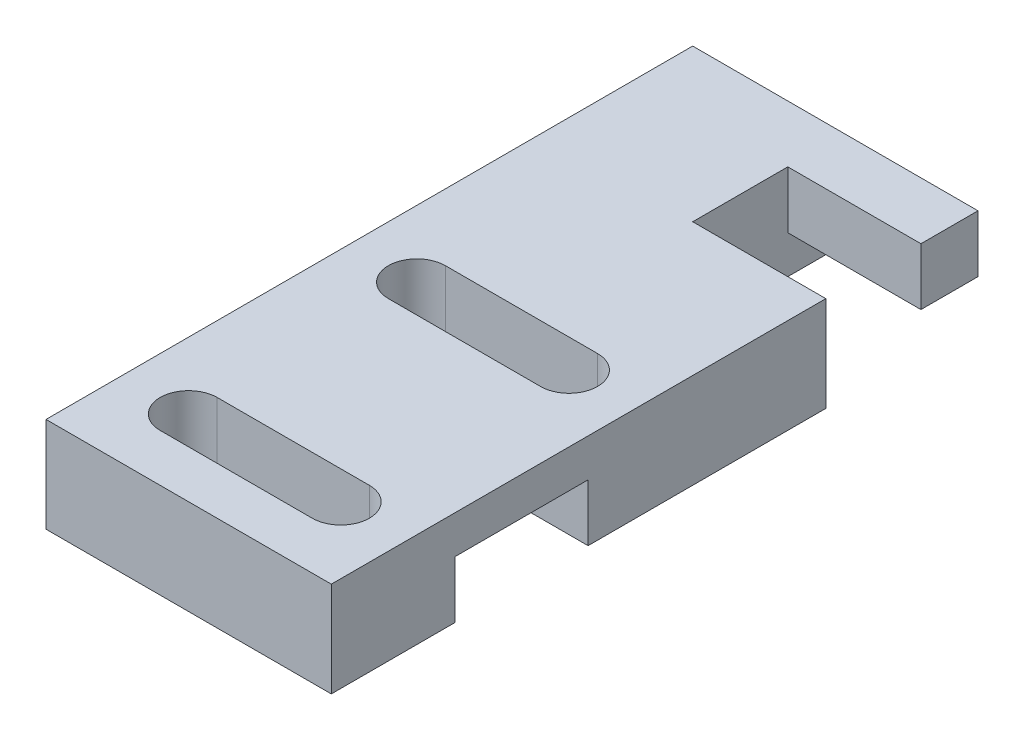
from build123d import *

# Parameters (mm, degrees)
EXTRUDE_1_DEPTH     = 5
SKETCH_2_W          = 7
SKETCH_2_H          = 3
CUT_EXTRUDE_1_DEPTH = 16
SKETCH_4_W          = 3
SKETCH_4_H          = 2
CUT_EXTRUDE_3_DEPTH = 16


with BuildPart() as part:
    # 草图1 → 凸台-拉伸1 (new body)
    with BuildSketch(Plane(origin=(0, 0, 0), x_dir=(1, 0, 0), z_dir=(0, 1, 0))):
        Polygon((15, 34), (0, 34), (0, 0), (15, 0), (15, 26), (8, 26), (8, 31), (15, 31), align=None)
        with BuildLine():
            ThreePointArc((3.5, 2.5), (2, 4), (3.5, 5.5))
            Line((3.5, 5.5), (11.5, 5.5))
            ThreePointArc((11.5, 5.5), (13, 4), (11.5, 2.5))
            Line((11.5, 2.5), (3.5, 2.5))
        make_face(mode=Mode.SUBTRACT)
        with BuildLine():
            ThreePointArc((3.5, 14.5), (2, 16), (3.5, 17.5))
            Line((3.5, 17.5), (11.5, 17.5))
            ThreePointArc((11.5, 17.5), (13, 16), (11.5, 14.5))
            Line((11.5, 14.5), (3.5, 14.5))
        make_face(mode=Mode.SUBTRACT)
    extrude(amount=EXTRUDE_1_DEPTH)

    # 草图2 → 切除-拉伸1 (cut, through all)
    with BuildSketch(Plane.ZY):
        with Locations((-10, 1.5)):
            Rectangle(SKETCH_2_W, SKETCH_2_H)
    extrude(amount=-CUT_EXTRUDE_1_DEPTH, mode=Mode.SUBTRACT)

    # 草图4 → 切除-拉伸3 (cut)
    with BuildSketch(Plane(origin=(8, 0, 0), x_dir=(0, 0, -1), z_dir=(1, 0, 0))):
        with Locations((32.5, 1)):
            Rectangle(SKETCH_4_W, SKETCH_4_H)
    extrude(amount=CUT_EXTRUDE_3_DEPTH, mode=Mode.SUBTRACT)


solid = part.part
